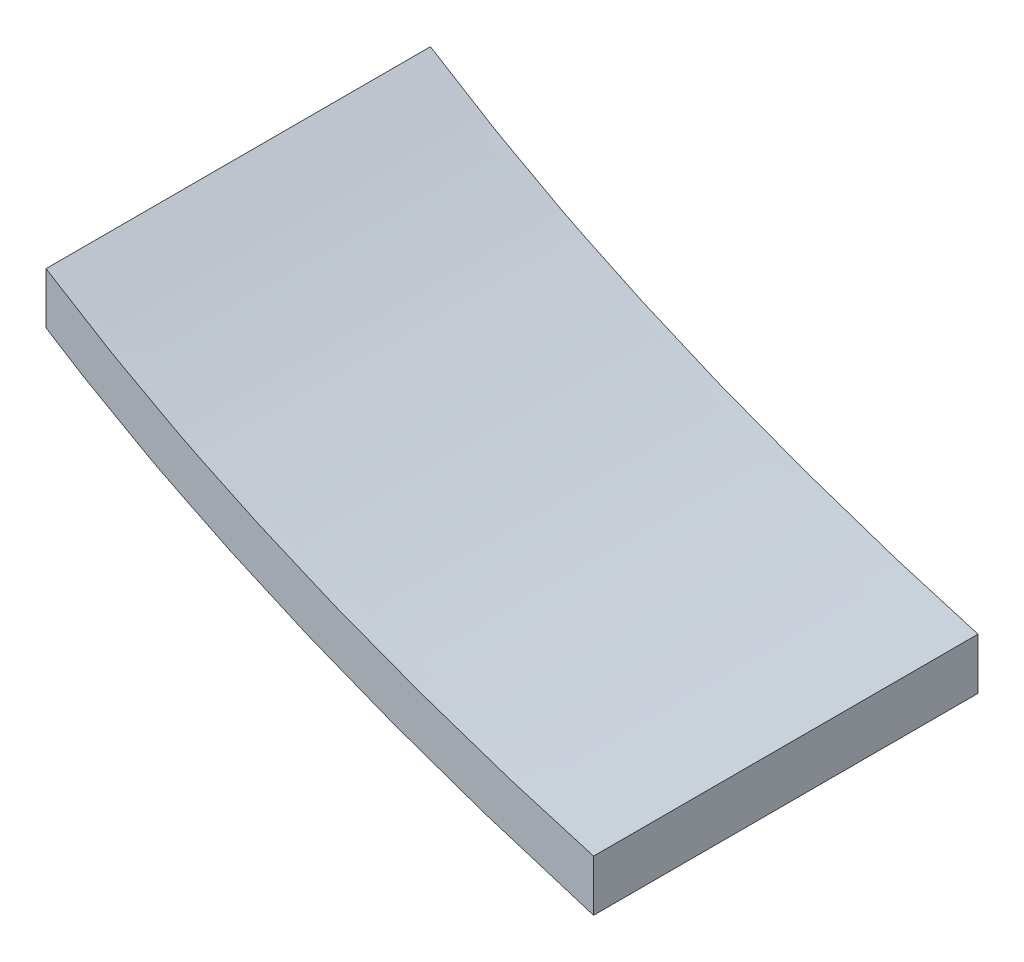
from build123d import *

# Parameters (mm, degrees)
BOSS_EXTRUDE1_DEPTH = 38.1


with BuildPart() as part:
    # Sketch2 → Boss-Extrude1 (new body)
    with BuildSketch(Plane.XY):
        with BuildLine():
            Line((-54.270006929, 28.369485347), (-54.270006929, 23.289485347))
            add(Edge.make_bspline(
                [(0, 0), (-0.021841284, 0.006411828), (-0.048536037, 0.014248462), (-0.080084258, 0.023509903), (-0.094611445, 0.027899146), (-3.628380224, 1.126039637), (-7.168604781, 2.226186302), (-10.715285115, 3.328339139), (-10.749064806, 3.339118272), (-10.805224015, 3.357509646), (-10.861382897, 3.375900913), (-10.917541451, 3.394292072), (-10.95111851, 3.405689952), (-13.903036516, 4.443319533), (-16.856288069, 5.48141787), (-19.810873171, 6.519984962), (-19.848214743, 6.533458759), (-19.910259966, 6.556427699), (-19.972304895, 6.579396531), (-20.034349532, 6.602365253), (-20.071428984, 6.616547106), (-22.777880406, 7.685185875), (-25.485891702, 8.754440558), (-28.195462872, 9.824311155), (-28.236880463, 9.841207083), (-28.305581773, 9.870140915), (-28.374283387, 9.899074875), (-28.442985306, 9.928008963), (-28.484049141, 9.94574486), (-30.968654634, 11.045808087), (-33.454983419, 12.146634304), (-35.943035495, 13.248223512), (-35.988779508, 13.269366036), (-36.064427224, 13.305822551), (-36.140076814, 13.34227997), (-36.215728279, 13.378738292), (-36.261041462, 13.400774799), (-38.006015898, 14.257071279), (-39.846229896, 15.160103859), (-41.781683454, 16.10987254), (-42.110618197, 16.276456429), (-42.793592661, 16.633207456), (-43.384342725, 16.94178516), (-43.882868391, 17.202189542), (-43.932632174, 17.228981774), (-44.014997323, 17.274665191), (-44.09736371, 17.320349295), (-44.179731335, 17.366034085), (-44.229082914, 17.393569505), (-45.815418452, 18.283904091), (-47.744736315, 19.366738321), (-50.017036503, 20.642072195), (-51.078921758, 21.277054046), (-52.49123083, 22.167715007), (-53.554925888, 22.838525441), (-54.270006929, 23.289485347)],
                knots=[0, 0, 0, 0, 0.001094005, 0.00133711, 0.001580214, 0.001823319, 0.179184037, 0.179752047, 0.180320057, 0.180888067, 0.182592146, 0.183160139, 0.183728133, 0.184296126, 0.333540977, 0.334176906, 0.334812835, 0.335448764, 0.337356616, 0.33799253, 0.338628444, 0.339264358, 0.47783902, 0.478555535, 0.47927205, 0.479988565, 0.482138247, 0.482854777, 0.483571308, 0.484287839, 0.61344735, 0.614254458, 0.615061567, 0.615868675, 0.618290315, 0.619097523, 0.619904731, 0.620711939, 0.712515716, 0.718421628, 0.72432754, 0.730233452, 0.755454125, 0.756359411, 0.757264697, 0.758169983, 0.760886055, 0.761791409, 0.762696763, 0.763602117, 0.849219058, 0.869027184, 0.88883531, 0.908643436, 0.949274089, 0.949274089, 0.949274089, 0.949274089], degree=3))
            Line((0, 0), (0, 5.08))
            add(Edge.make_bspline(
                [(0, 5.08), (-2.662996604, 5.868926123), (-5.337259413, 6.661189917), (-8.022788428, 7.45679138), (-8.056511999, 7.467061284), (-8.112584124, 7.484603293), (-8.168655921, 7.502145198), (-8.224727392, 7.519687002), (-8.258257689, 7.530574694), (-11.206534394, 8.523142193), (-14.156143002, 9.516158091), (-17.107083513, 10.509622388), (-17.144383615, 10.52252411), (-17.206367607, 10.544539097), (-17.268351307, 10.566553981), (-17.330334714, 10.58856876), (-17.367383582, 10.602177839), (-20.072044847, 11.628812714), (-22.778264954, 12.656039295), (-25.486043902, 13.68385758), (-25.527441256, 13.700107525), (-25.596120981, 13.727964504), (-25.66480101, 13.755821606), (-25.733481343, 13.783678831), (-25.774538107, 13.800768482), (-28.259071326, 14.861571755), (-30.745327787, 15.923110789), (-33.23330749, 16.985385583), (-33.27906191, 17.00580007), (-33.354746545, 17.041043848), (-33.430433054, 17.0762885), (-33.506121438, 17.111534025), (-33.551459361, 17.13284293), (-35.297488017, 17.96107491), (-37.138813773, 18.834511249), (-39.075436629, 19.753151946), (-39.404638324, 19.914415205), (-40.088310549, 20.260055047), (-40.679664154, 20.559021948), (-41.178699139, 20.811315908), (-41.2285243, 20.837293854), (-41.311008712, 20.881621663), (-41.393494364, 20.925950139), (-41.475981256, 20.970279281), (-41.525406444, 20.997001491), (-43.114177327, 21.861165789), (-45.046457083, 22.912171441), (-47.32224571, 24.150018448), (-48.386275951, 24.767252984), (-50.696988145, 26.181954349), (-52.658231804, 27.38269847), (-54.270006929, 28.369485347)],
                knots=[0.044923341, 0.044923341, 0.044923341, 0.044923341, 0.179184037, 0.179752047, 0.180320057, 0.180888067, 0.182592146, 0.183160139, 0.183728133, 0.184296126, 0.333540977, 0.334176906, 0.334812835, 0.335448764, 0.337356616, 0.33799253, 0.338628444, 0.339264358, 0.47783902, 0.478555535, 0.47927205, 0.479988565, 0.482138247, 0.482854777, 0.483571308, 0.484287839, 0.61344735, 0.614254458, 0.615061567, 0.615868675, 0.618290315, 0.619097523, 0.619904731, 0.620711939, 0.712515716, 0.718421628, 0.72432754, 0.730233452, 0.755454125, 0.756359411, 0.757264697, 0.758169983, 0.760886055, 0.761791409, 0.762696763, 0.763602117, 0.849219058, 0.869027184, 0.88883531, 0.908643436, 1, 1, 1, 1], degree=3))
        make_face()
    extrude(amount=BOSS_EXTRUDE1_DEPTH)


solid = part.part
